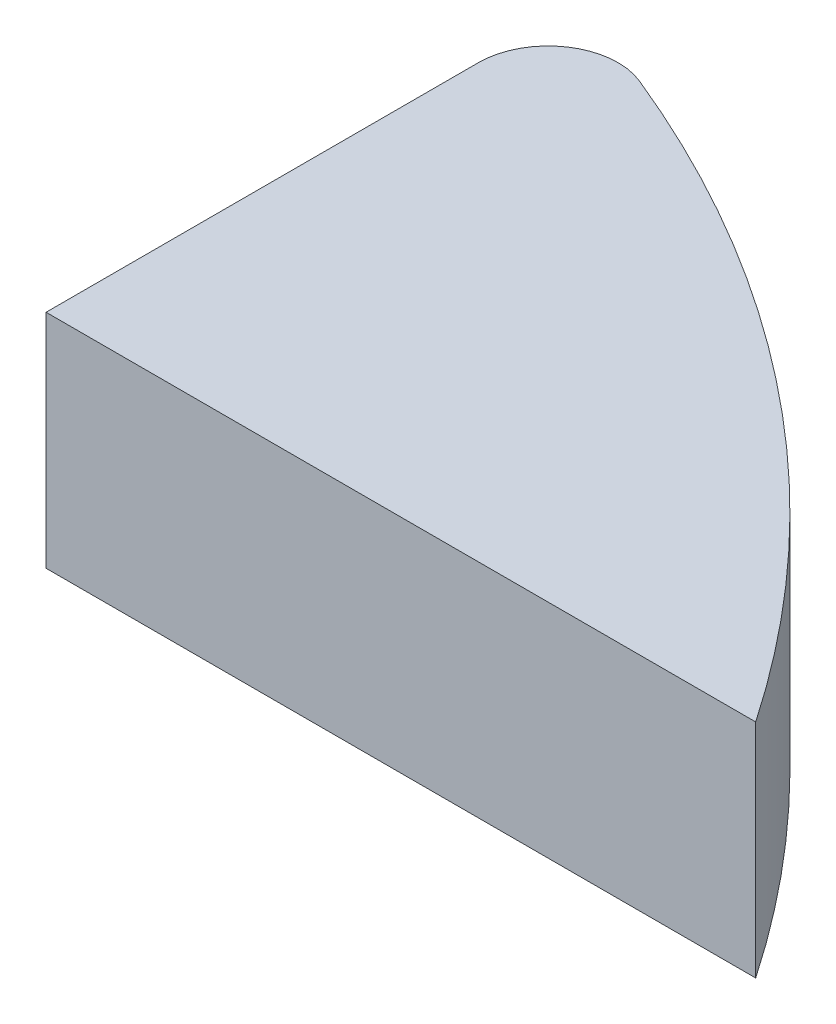
from build123d import *

# Parameters (mm, degrees)
BOSS_EXTRUDE1_DEPTH = 6.35
FILLET1_R           = 2


with BuildPart() as part:
    # Sketch1 → Boss-Extrude1 (new body)
    with BuildSketch(Plane(origin=(0, 0, 0), x_dir=(1, 0, 0), z_dir=(0, 1, 0))):
        with BuildLine():
            Line((0, 0), (0, 15.24))
            ThreePointArc((0, 15.24), (11.430567272, 9.314089696), (20.32, 0))
            Line((20.32, 0), (0, 0))
        make_face()
    extrude(amount=BOSS_EXTRUDE1_DEPTH)

    # Fillet1
    fillet1_edges = [part.edges().sort_by_distance(p)[0] for p in [
        (0, 3.175, -15.24),
    ]]
    fillet(fillet1_edges, radius=FILLET1_R)


solid = part.part
